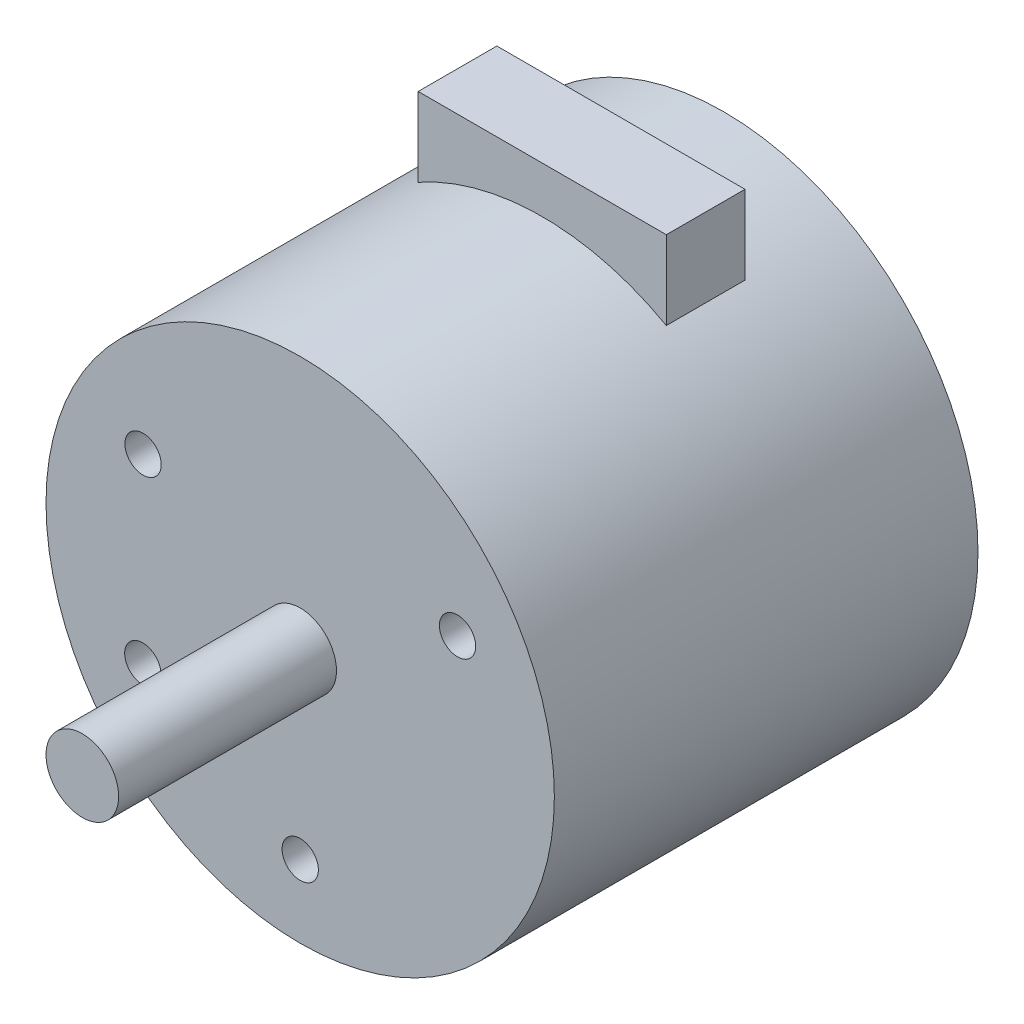
from build123d import *

# Parameters (mm, degrees)
SKETCH_1_R          = 21
EXTRUDE_1_DEPTH     = 35
SKETCH_2_R          = 3
EXTRUDE_2_DEPTH     = 18
EXTRUDE_4_DEPTH     = 6.5
SKETCH_7_R          = 1.5
CUT_EXTRUDE_1_DEPTH = 6.5
MM_PRESS_1_D        = 3
MM_PRESS_2_D        = 3


with BuildPart() as part:
    # 草图1 → 凸台-拉伸1 (new body)
    with BuildSketch(Plane.XY):
        Circle(SKETCH_1_R)
    extrude(amount=EXTRUDE_1_DEPTH)

    # 草图2 → 凸台-拉伸2 (add)
    with BuildSketch(Plane.XY.offset(35)):
        Circle(SKETCH_2_R)
    extrude(amount=EXTRUDE_2_DEPTH)

    # 草图6 → 凸台-拉伸4 (add)
    with BuildSketch(Plane(origin=(0, 0, 15), x_dir=(-1, 0, 0), z_dir=(0, 0, -1))):
        with BuildLine():
            Line((-10.25, 18.328597873), (-10.25, 24.828597873))
            Line((-10.25, 24.828597873), (10.25, 24.828597873))
            Line((10.25, 24.828597873), (10.25, 18.328597873))
            ThreePointArc((10.25, 18.328597873), (0, 21), (-10.25, 18.328597873))
        make_face()
    extrude(amount=EXTRUDE_4_DEPTH)

    # 草图7 → 切除-拉伸1 (cut)
    with BuildSketch(Plane.XY.offset(35)):
        with Locations((13, 7.5)):
            Circle(SKETCH_7_R)
        with Locations((0.002409407, -14.995836032)):
            Circle(SKETCH_7_R)
        with Locations((-12.98076078, 7.508325625)):
            Circle(SKETCH_7_R)
        with Locations((-13, -7.5)):
            Circle(SKETCH_7_R)
    extrude(amount=-CUT_EXTRUDE_1_DEPTH, mode=Mode.SUBTRACT)

    # 大小mm Press 暗销孔1 (through all)
    with Locations(Plane(origin=(19.777789767, 155.433675327, 28.5), x_dir=(0.242616345, -0.970122317, 0), z_dir=(0, 0, 1))):
        with Locations((141.869357239, -42.466412685)):
            Hole(MM_PRESS_1_D / 2)

    # 大小mm Press 暗销孔2 (through all)
    with Locations(Plane(origin=(19.777789767, 155.433675327, 28.5), x_dir=(0.242616345, -0.970122317, 0), z_dir=(0, 0, 1))):
        with Locations((150.113167025, -71.32883809)):
            Hole(MM_PRESS_2_D / 2)


solid = part.part
